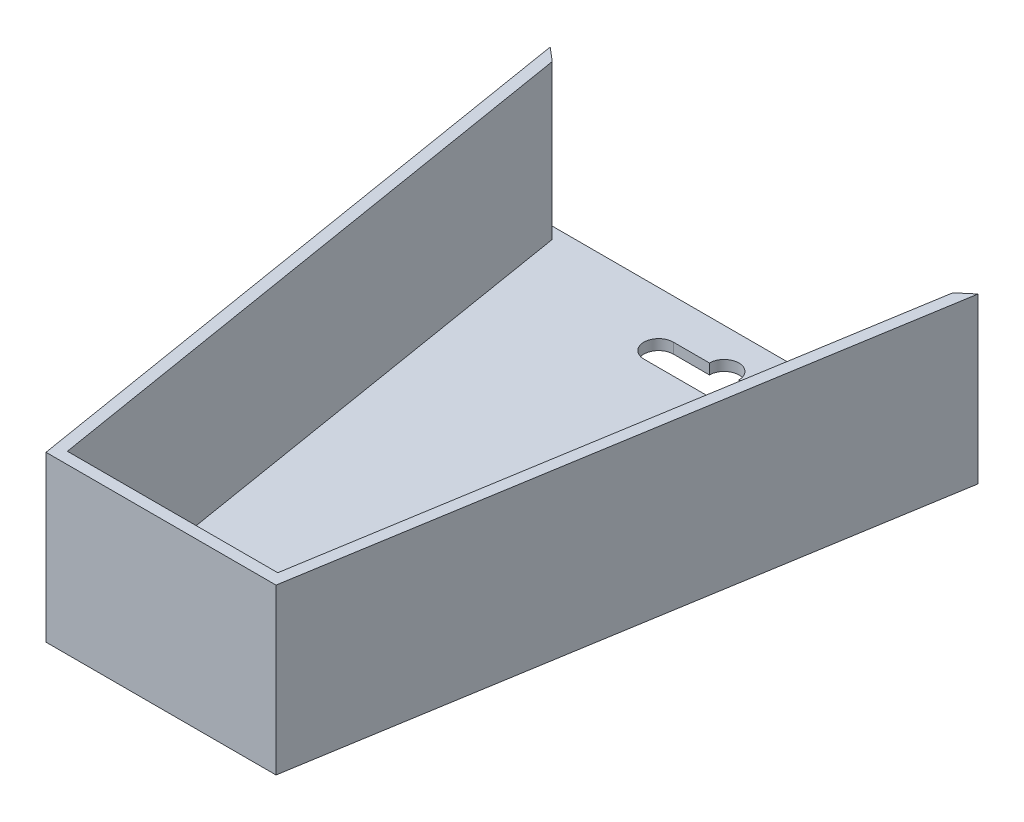
from build123d import *

# Parameters (mm, degrees)
BASE_DEPTH  = 2.286
WALLS_DEPTH = 36.1315


with BuildPart() as part:
    # Sketch1 → Base (new body)
    with BuildSketch(Plane(origin=(0, 0, 0), x_dir=(1, 0, 0), z_dir=(0, 1, 0))):
        Polygon((25.26665, -132.4864), (46.99, 0), (-46.99, 0), (-25.26665, -132.4864), align=None)
        with BuildLine():
            ThreePointArc((11.1633, -8.773780407), (14.396409796, -12.006890204), (11.1633, -15.24))
            Line((11.1633, -15.24), (-11.1633, -15.24))
            ThreePointArc((-11.1633, -15.24), (-14.396409796, -12.006890204), (-11.1633, -8.773780407))
            Line((-11.1633, -8.773780407), (-3.233109796, -8.773780407))
            ThreePointArc((-3.233109796, -8.773780407), (0, -5.540670611), (3.233109796, -8.773780407))
            Line((3.233109796, -8.773780407), (11.1633, -8.773780407))
        make_face(mode=Mode.SUBTRACT)
    extrude(amount=BASE_DEPTH)

    # Sketch1_4 → Walls (add)
    with BuildSketch(Plane(origin=(0, 0, 0), x_dir=(1, 0, 0), z_dir=(0, 1, 0))):
        Polygon((-43.999607163, -2.54), (-46.99, 0), (-25.26665, -132.4864), (25.26665, -132.4864), (46.99, 0), (43.999607163, -2.54), (23.1092077, -129.9464), (-23.1092077, -129.9464), align=None)
    extrude(amount=WALLS_DEPTH)


solid = part.part
